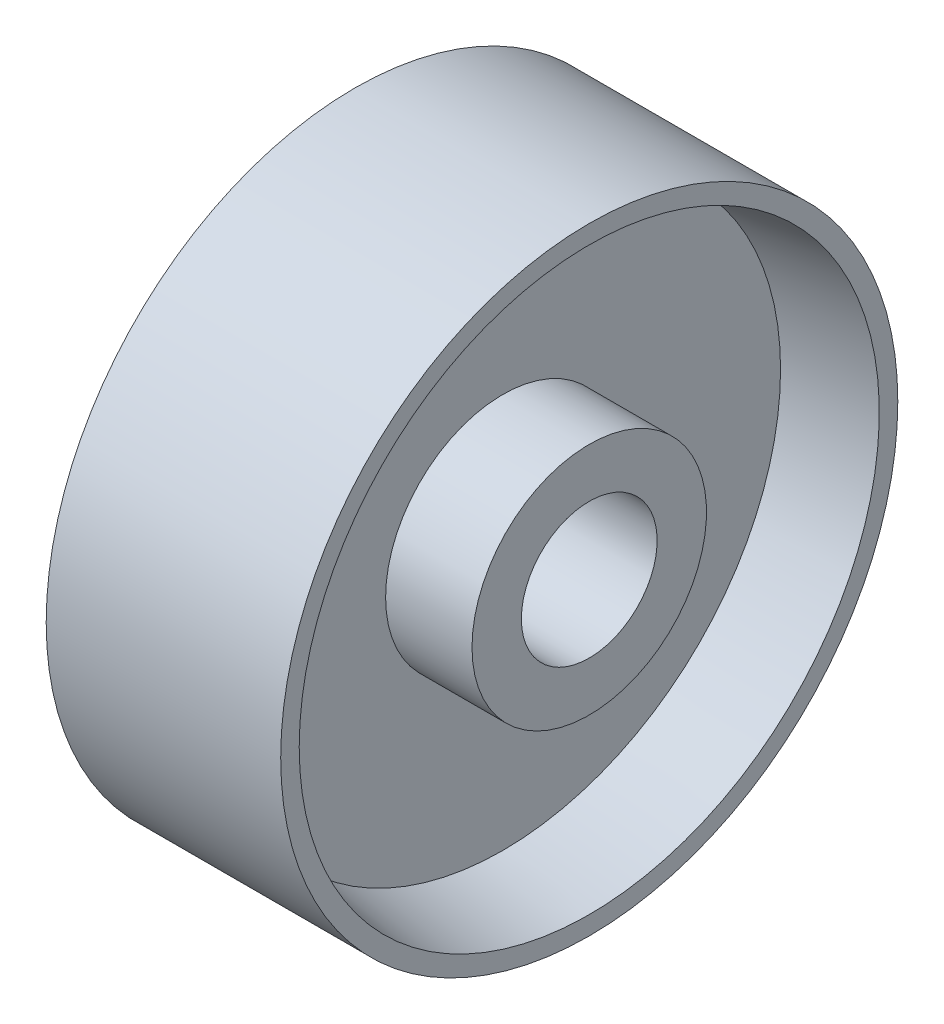
from build123d import *


with BuildPart() as part:
    # Croquis1 → Revolución1 (revolve)
    with BuildSketch(Plane.XY):
        Polygon((19, 11), (-19, 11), (-19, 19), (-5, 19), (-5, 45), (-19, 47), (-19, 50), (19, 50), (19, 47), (5, 45), (5, 19), (19, 19), align=None)
    revolve(axis=Axis((-14.761290323, 0, 0), (1, 0, 0)))


solid = part.part
